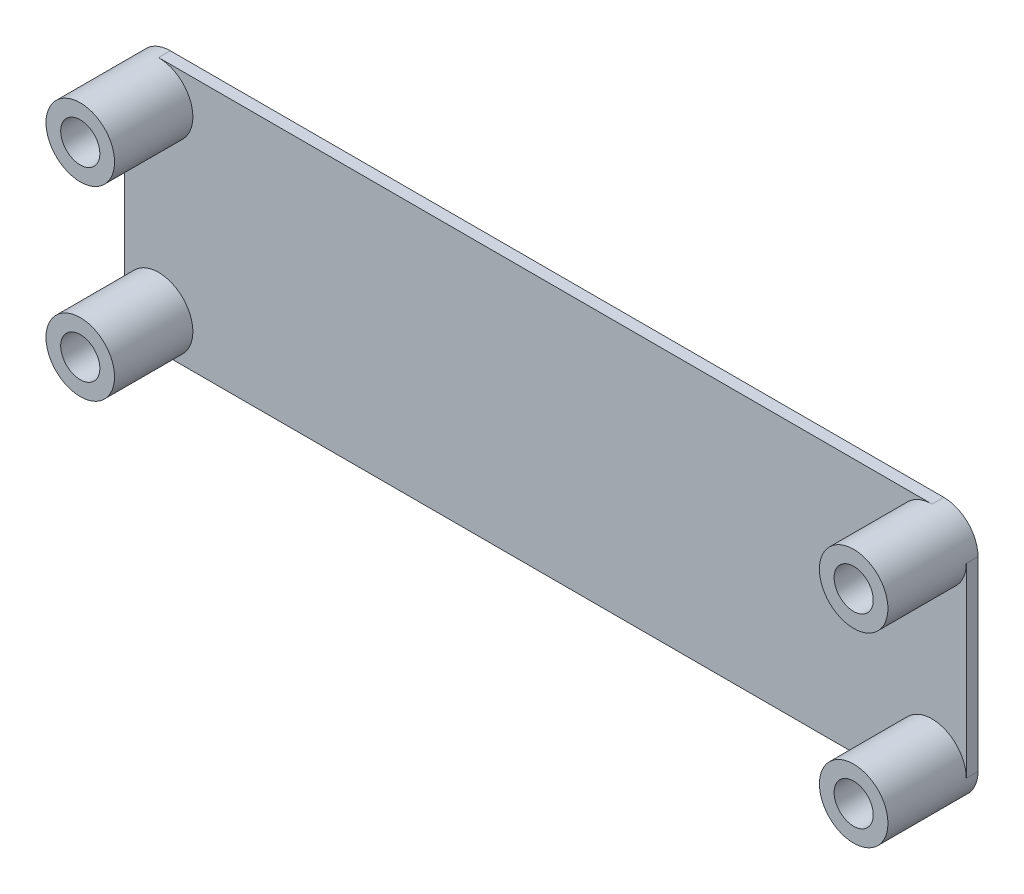
from build123d import *

# Parameters (mm, degrees)
EXTRUDE_1_DEPTH     = 1.2
EXTRUDE_START       = 1.2
SKETCH_1_3_R        = 3.5
EXTRUDE_2_DEPTH     = 8
SKETCH_2_R          = 2
CUT_EXTRUDE_1_DEPTH = 6


with BuildPart() as part:
    # Эскиз1 → Бобышка-Вытянуть1 (new body)
    with BuildSketch(Plane.XY):
        with BuildLine():
            Line((0, 22.5), (0, 3.5))
            ThreePointArc((0, 3.5), (1.025126266, 1.025126266), (3.5, 0))
            Line((3.5, 0), (82.5, 0))
            ThreePointArc((82.5, 0), (84.974873734, 1.025126266), (86, 3.5))
            Line((86, 3.5), (86, 22.5))
            ThreePointArc((86, 22.5), (84.974873734, 24.974873734), (82.5, 26))
            Line((82.5, 26), (3.5, 26))
            ThreePointArc((3.5, 26), (1.025126266, 24.974873734), (0, 22.5))
        make_face()
    extrude(amount=EXTRUDE_1_DEPTH)

    # Эскиз1<3> → Бобышка-Вытянуть2 (add)
    with BuildSketch(Plane.XY.offset(EXTRUDE_START)):
        with Locations((82.5, 22.5)):
            Circle(SKETCH_1_3_R)
        with Locations((82.5, 3.5)):
            Circle(SKETCH_1_3_R)
        with Locations((3.5, 22.5)):
            Circle(SKETCH_1_3_R)
        with Locations((3.5, 3.5)):
            Circle(SKETCH_1_3_R)
    extrude(amount=EXTRUDE_2_DEPTH)

    # Эскиз2 → Вырез-Вытянуть1 (cut)
    with BuildSketch(Plane.XY.offset(9.2)):
        with Locations((3.5, 22.5)):
            Circle(SKETCH_2_R)
        with Locations((3.5, 3.5)):
            Circle(SKETCH_2_R)
        with Locations((82.5, 22.5)):
            Circle(SKETCH_2_R)
        with Locations((82.5, 3.5)):
            Circle(SKETCH_2_R)
    extrude(amount=-CUT_EXTRUDE_1_DEPTH, mode=Mode.SUBTRACT)


solid = part.part
